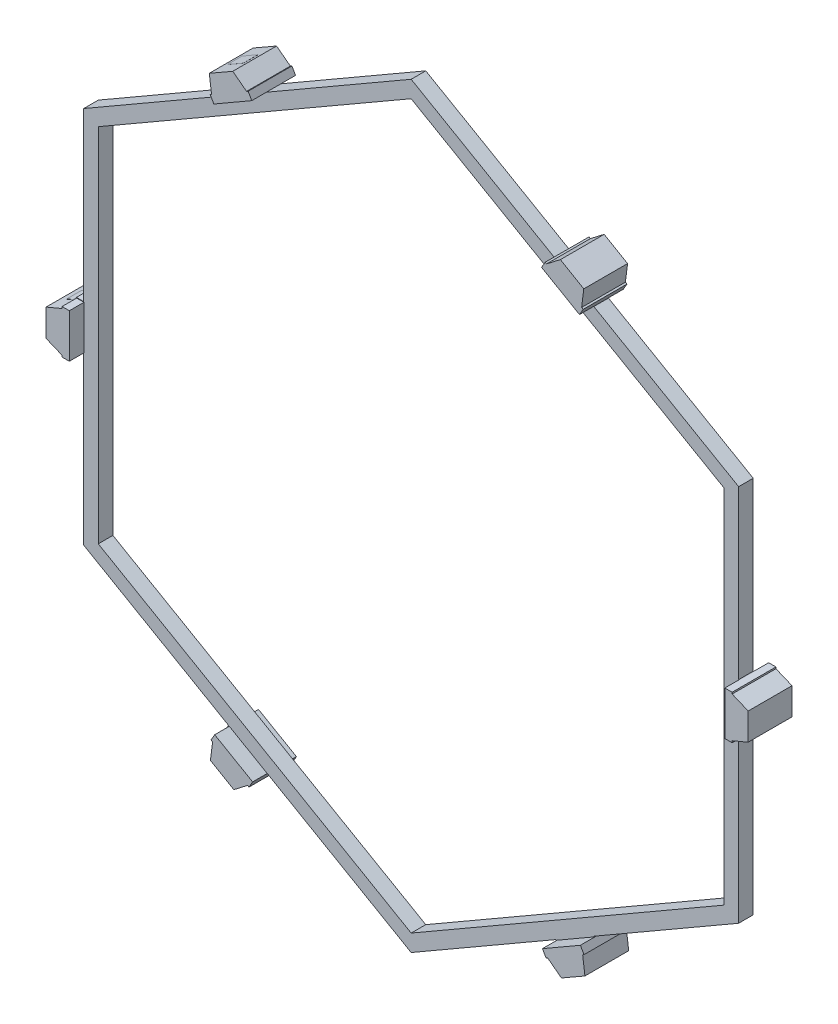
from build123d import *

# Parameters (mm, degrees)
BOSS_EXTRUDE1_DEPTH      = 1
BOSS_EXTRUDE2_DEPTH      = 1
BOSS_EXTRUDE2_DEPTH_BACK = 2


with BuildPart() as part:
    # Sketch1 → Boss-Extrude1 (new body)
    with BuildSketch(Plane.XY):
        with BuildLine():
            Line((22.397016434, 12.952378094), (12.476954775, 18.679728363))
            Line((12.476954775, 18.679728363), (12.726954775, 19.112741065))
            Line((12.726954775, 19.112741065), (12.516198987, 19.234420976))
            ThreePointArc((12.516198987, 19.234420976), (12.68450037, 19.874654921), (12.504090028, 20.511582679))
            Line((12.504090028, 20.511582679), (11.404603705, 21.146371403))
            ThreePointArc((11.404603705, 21.146371403), (10.775926893, 20.968706558), (10.316076863, 20.504662076))
            Line((10.316076863, 20.504662076), (10.128878563, 20.612741065))
            Line((10.128878563, 20.612741065), (9.878878563, 20.179728363))
            Line((9.878878563, 20.179728363), (-0.03711231, 25.904728363))
            Line((-0.03711231, 25.904728363), (-9.957173969, 20.177378094))
            Line((-9.957173969, 20.177378094), (-10.207173969, 20.610390796))
            Line((-10.207173969, 20.610390796), (-10.417929757, 20.488710885))
            ThreePointArc((-10.417929757, 20.488710885), (-10.888237926, 20.954581131), (-11.530038716, 21.116805071))
            Line((-11.530038716, 21.116805071), (-12.629525039, 20.482016346))
            ThreePointArc((-12.629525039, 20.482016346), (-12.790001175, 19.848733833), (-12.618051881, 19.218469784))
            Line((-12.618051881, 19.218469784), (-12.80525018, 19.110390796))
            Line((-12.80525018, 19.110390796), (-12.55525018, 18.677378094))
            Line((-12.55525018, 18.677378094), (-22.471241054, 12.952378094))
            Line((-22.471241054, 12.952378094), (-22.471241054, 1.901120277))
            Line((-22.471241054, 1.901120277), (-22.471241054, 1.497677556))
            Line((-22.471241054, 1.497677556), (-22.971241054, 1.497677556))
            Line((-22.971241054, 1.497677556), (-22.971241054, 1.254317734))
            ThreePointArc((-22.971241054, 1.254317734), (-23.609850606, 1.079954035), (-24.071241054, 0.605250217))
            Line((-24.071241054, 0.605250217), (-24.071241054, -0.664327233))
            ThreePointArc((-24.071241054, -0.664327233), (-23.603040378, -1.1199449), (-22.971241054, -1.286164467))
            Line((-22.971241054, -1.286164467), (-22.971241054, -1.502322444))
            Line((-22.971241054, -1.502322444), (-22.471241054, -1.502322444))
            Line((-22.471241054, -1.502322444), (-22.471241054, -1.596383326))
            Line((-22.471241054, -1.596383326), (-22.471241054, -12.952322444))
            Line((-22.471241054, -12.952322444), (-12.630090814, -18.634113185))
            Line((-12.630090814, -18.634113185), (-12.551179395, -18.679672714))
            Line((-12.551179395, -18.679672714), (-12.801179395, -19.112685416))
            Line((-12.801179395, -19.112685416), (-12.590423607, -19.234365326))
            ThreePointArc((-12.590423607, -19.234365326), (-12.758724991, -19.874599271), (-12.578314648, -20.511527029))
            Line((-12.578314648, -20.511527029), (-11.478828325, -21.146315754))
            ThreePointArc((-11.478828325, -21.146315754), (-10.850151513, -20.968650909), (-10.390301483, -20.504606427))
            Line((-10.390301483, -20.504606427), (-10.203103183, -20.612685416))
            Line((-10.203103183, -20.612685416), (-9.953103183, -20.179672714))
            Line((-9.953103183, -20.179672714), (-9.931256757, -20.192285754))
            Line((-9.931256757, -20.192285754), (-0.03711231, -25.904672714))
            Line((-0.03711231, -25.904672714), (9.790701603, -20.230581705))
            Line((9.790701603, -20.230581705), (9.882949349, -20.177322444))
            Line((9.882949349, -20.177322444), (10.132949349, -20.610335146))
            Line((10.132949349, -20.610335146), (10.343705136, -20.488655236))
            ThreePointArc((10.343705136, -20.488655236), (10.814013306, -20.954525482), (11.455814095, -21.116749421))
            Line((11.455814095, -21.116749421), (12.555300419, -20.481960696))
            ThreePointArc((12.555300419, -20.481960696), (12.715776555, -19.848678184), (12.543827261, -19.218414135))
            Line((12.543827261, -19.218414135), (12.73102556, -19.110335146))
            Line((12.73102556, -19.110335146), (12.48102556, -18.677322444))
            Line((12.48102556, -18.677322444), (12.549124227, -18.638005661))
            Line((12.549124227, -18.638005661), (22.397016434, -12.952322444))
            Line((22.397016434, -12.952322444), (22.397016434, -1.497621906))
            Line((22.397016434, -1.497621906), (22.897016434, -1.497621906))
            Line((22.897016434, -1.497621906), (22.897016434, -1.254262085))
            ThreePointArc((22.897016434, -1.254262085), (23.535625986, -1.079898386), (23.997016434, -0.605194567))
            Line((23.997016434, -0.605194567), (23.997016434, 0.664382882))
            ThreePointArc((23.997016434, 0.664382882), (23.528815758, 1.120000549), (22.897016434, 1.286220117))
            Line((22.897016434, 1.286220117), (22.897016434, 1.502378094))
            Line((22.897016434, 1.502378094), (22.397016434, 1.502378094))
            Line((22.397016434, 1.502378094), (22.397016434, 12.952378094))
        make_face()
        Polygon((21.397016434, 12.375027825), (-0.03711231, 24.750027825), (-21.471241054, 12.375027825), (-21.471241054, -12.374972175), (-0.03711231, -24.749972175), (21.397016434, -12.374972175), align=None, mode=Mode.SUBTRACT)
    extrude(amount=BOSS_EXTRUDE1_DEPTH)

    # Sketch2 → Boss-Extrude2 (add, two sides)
    with BuildSketch(Plane.XY.offset(1)) as boss_extrude2_sk:
        Polygon((-12.55525018, 18.677378094), (-9.957173969, 20.177378094), (-10.207173969, 20.610390796), (-10.312551863, 20.54955084), (-11.258459696, 21.268059485), (-12.867222828, 20.344781463), (-12.711651031, 19.16443029), (-12.80525018, 19.110390796), align=None)
        Polygon((11.185486168, 21.315732577), (12.789449955, 20.384141846), (12.640157133, 19.205707311), (12.745535027, 19.144867356), (12.495535027, 18.711854654), (9.897458815, 20.211854654), (10.147458815, 20.644867356), (10.241057965, 20.590827862), align=None)
        Polygon((24.052708996, 0.970951113), (24.047909651, -0.883917639), (22.952708996, -1.343843529), (22.952708996, -1.46552344), (22.452708996, -1.46552344), (22.452708996, 1.53447656), (22.952708996, 1.53447656), (22.952708996, 1.426397572), align=None)
        Polygon((12.867222828, -20.344781463), (11.258459696, -21.268059485), (10.312551863, -20.54955084), (10.207173969, -20.610390796), (9.957173969, -20.177378094), (12.55525018, -18.677378094), (12.80525018, -19.110390796), (12.711651031, -19.16443029), align=None)
        Polygon((-11.185486168, -21.315732577), (-12.789449955, -20.384141846), (-12.640157133, -19.205707311), (-12.745535027, -19.144867356), (-12.495535027, -18.711854654), (-9.897458815, -20.211854654), (-10.147458815, -20.644867356), (-10.241057965, -20.590827862), align=None)
        Polygon((-24.052708996, -0.970951113), (-24.047909651, 0.883917639), (-22.952708996, 1.343843529), (-22.952708996, 1.46552344), (-22.452708996, 1.46552344), (-22.452708996, -1.53447656), (-22.952708996, -1.53447656), (-22.952708996, -1.426397572), align=None)
    extrude(amount=BOSS_EXTRUDE2_DEPTH)
    extrude(boss_extrude2_sk.sketch, amount=-BOSS_EXTRUDE2_DEPTH_BACK)


solid = part.part
